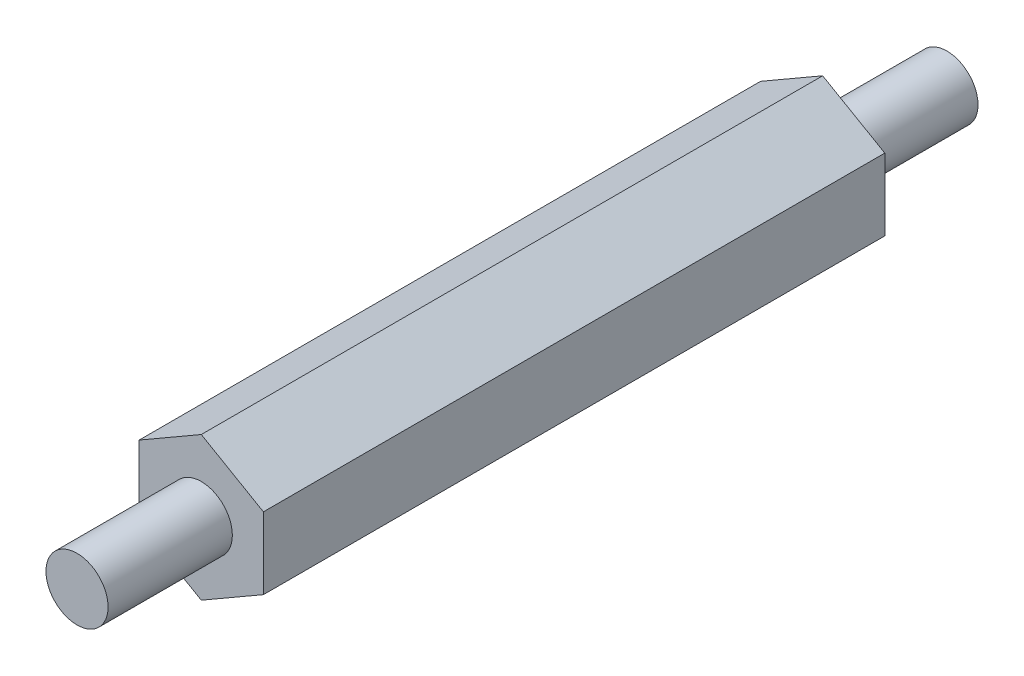
from build123d import *

# Parameters (mm, degrees)
BOSS_EXTRUDE1_DEPTH = 30
SKETCH2_R           = 1.5
BOSS_EXTRUDE2_DEPTH = 6
SKETCH3_R           = 1.5
BOSS_EXTRUDE3_DEPTH = 6


with BuildPart() as part:
    # Sketch1 → Boss-Extrude1 (new body)
    with BuildSketch(Plane.XY):
        Polygon((-0.918598934, -3.331524887), (2.081401066, -1.599474079), (2.081401066, 1.864627536), (-0.918598934, 3.596678344), (-3.918598934, 1.864627536), (-3.918598934, -1.599474079), align=None)
    extrude(amount=BOSS_EXTRUDE1_DEPTH)

    # Sketch2 → Boss-Extrude2 (add)
    with BuildSketch(Plane.XY.offset(30)):
        with Locations((-0.918598934, 0.132576728)):
            Circle(SKETCH2_R)
    extrude(amount=BOSS_EXTRUDE2_DEPTH)

    # Sketch3 → Boss-Extrude3 (add)
    with BuildSketch(Plane(origin=(0, 0, 0), x_dir=(-1, 0, 0), z_dir=(0, 0, -1))):
        with Locations((0.918598934, 0.132576728)):
            Circle(SKETCH3_R)
    extrude(amount=BOSS_EXTRUDE3_DEPTH)


solid = part.part
